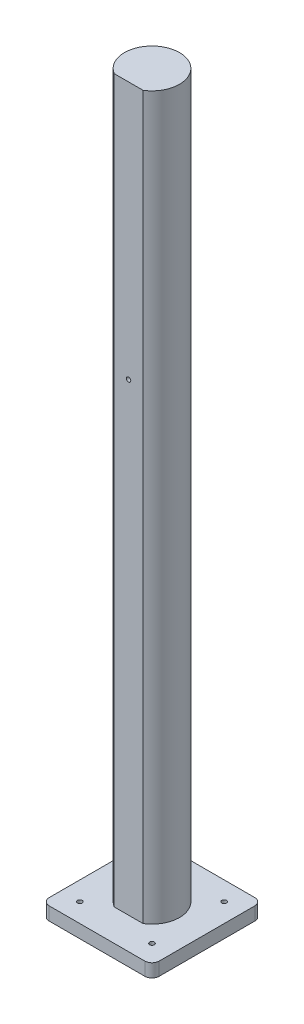
from build123d import *

# Parameters (mm, degrees)
BOSS_EXTRUDE1_DEPTH = 500
SKETCH5_R           = 1.5
CUT_EXTRUDE1_DEPTH  = 5
SKETCH6_W           = 76.2
SKETCH6_H           = 76.2
BOSS_EXTRUDE2_DEPTH = 9.144
SKETCH7_R           = 1.65
CUT_EXTRUDE2_DEPTH  = 9.144
FILLET1_R           = 5


with BuildPart() as part:
    # Sketch3 → Boss-Extrude1 (new body)
    with BuildSketch(Plane(origin=(0, 0, 0), x_dir=(1, 0, 0), z_dir=(0, 1, 0))):
        with BuildLine():
            Line((-10, -16.214268408), (10, -16.214268408))
            ThreePointArc((10, -16.214268408), (0, 19.05), (-10, -16.214268408))
        make_face()
    extrude(amount=BOSS_EXTRUDE1_DEPTH)

    # Sketch5 → Cut-Extrude1 (cut)
    with BuildSketch(Plane.XY.offset(16.214268408)):
        with Locations((0, 321.4)):
            Circle(SKETCH5_R)
    extrude(amount=-CUT_EXTRUDE1_DEPTH, mode=Mode.SUBTRACT)

    # Sketch6 → Boss-Extrude2 (add)
    with BuildSketch(Plane.XZ):
        Rectangle(SKETCH6_W, SKETCH6_H)
    extrude(amount=BOSS_EXTRUDE2_DEPTH)

    # Sketch7 → Cut-Extrude2 (cut)
    with BuildSketch(Plane.XZ.offset(9.144)):
        with Locations((-25, 25)):
            Circle(SKETCH7_R)
        with Locations((25, 25)):
            Circle(SKETCH7_R)
        with Locations((25, -25)):
            Circle(SKETCH7_R)
        with Locations((-25, -25)):
            Circle(SKETCH7_R)
    extrude(amount=-CUT_EXTRUDE2_DEPTH, mode=Mode.SUBTRACT)

    # Fillet1
    fillet1_edges = [part.edges().sort_by_distance(p)[0] for p in [
        (38.1, -4.572, -38.1),
        (38.1, -4.572, 38.1),
        (-38.1, -4.572, 38.1),
        (-38.1, -4.572, -38.1),
    ]]
    fillet(fillet1_edges, radius=FILLET1_R)


solid = part.part
